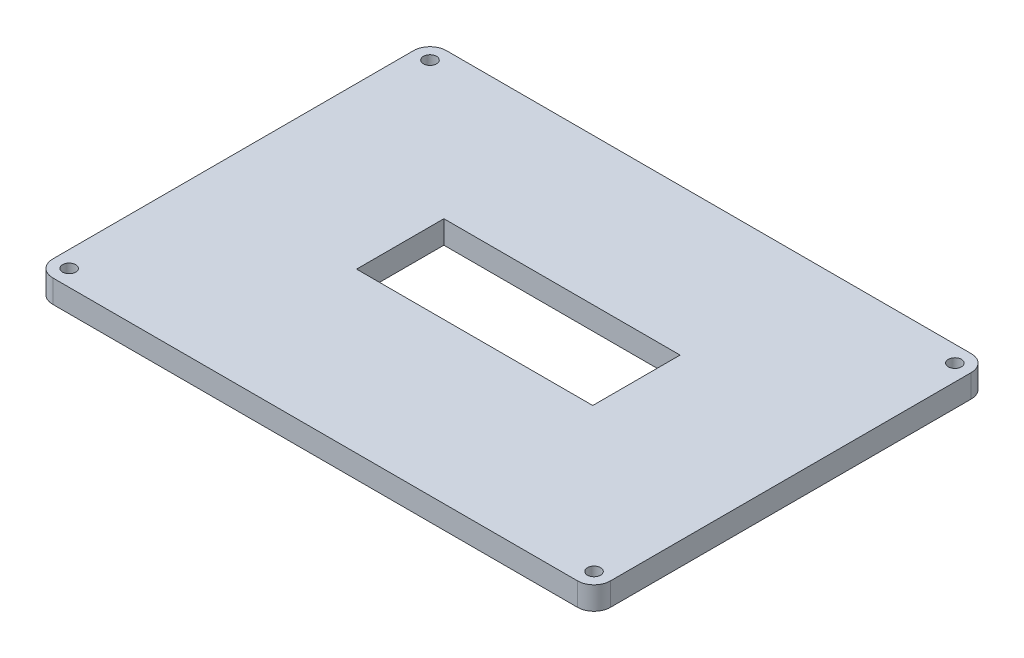
from build123d import *

# Parameters (mm, degrees)
SKETCH1_W           = 170
SKETCH1_H           = 120
BOSS_EXTRUDE1_DEPTH = 7
SKETCH2_W           = 72
SKETCH2_H           = 26.620567464
CUT_EXTRUDE1_DEPTH  = 7
SKETCH3_R           = 2
CUT_EXTRUDE5_DEPTH  = 7
SKETCH7_R           = 2
CUT_EXTRUDE7_DEPTH  = 10
SKETCH6_R           = 2
CUT_EXTRUDE10_DEPTH = 10
SKETCH9_R           = 2
CUT_EXTRUDE11_DEPTH = 10
FILLET1_R           = 5


with BuildPart() as part:
    # Sketch1 → Boss-Extrude1 (new body)
    with BuildSketch(Plane(origin=(0, 0, 0), x_dir=(1, 0, 0), z_dir=(0, 1, 0))):
        Rectangle(SKETCH1_W, SKETCH1_H)
    extrude(amount=BOSS_EXTRUDE1_DEPTH)

    # Sketch2 → Cut-Extrude1 (cut)
    with BuildSketch(Plane(origin=(0, 7, 0), x_dir=(1, 0, 0), z_dir=(0, 1, 0))):
        with Locations((0, 1.926488435)):
            Rectangle(SKETCH2_W, SKETCH2_H)
    extrude(amount=-CUT_EXTRUDE1_DEPTH, mode=Mode.SUBTRACT)

    # Sketch3 → Cut-Extrude5 (cut)
    with BuildSketch(Plane(origin=(0, 7, 0), x_dir=(1, 0, 0), z_dir=(0, 1, 0))):
        with Locations((-80, 55)):
            Circle(SKETCH3_R)
    extrude(amount=-CUT_EXTRUDE5_DEPTH, mode=Mode.SUBTRACT)

    # Sketch7 → Cut-Extrude7 (cut)
    with BuildSketch(Plane(origin=(0, 7, 0), x_dir=(1, 0, 0), z_dir=(0, 1, 0))):
        with Locations((-80, -55)):
            Circle(SKETCH7_R)
    extrude(amount=-CUT_EXTRUDE7_DEPTH, mode=Mode.SUBTRACT)

    # Sketch6 → Cut-Extrude10 (cut)
    with BuildSketch(Plane(origin=(0, 7, 0), x_dir=(1, 0, 0), z_dir=(0, 1, 0))):
        with Locations((80, 55)):
            Circle(SKETCH6_R)
    extrude(amount=-CUT_EXTRUDE10_DEPTH, mode=Mode.SUBTRACT)

    # Sketch9 → Cut-Extrude11 (cut)
    with BuildSketch(Plane(origin=(0, 7, 0), x_dir=(1, 0, 0), z_dir=(0, 1, 0))):
        with Locations((80, -55)):
            Circle(SKETCH9_R)
    extrude(amount=-CUT_EXTRUDE11_DEPTH, mode=Mode.SUBTRACT)

    # Fillet1
    fillet1_edges = [part.edges().sort_by_distance(p)[0] for p in [
        (-85, 3.5, -60),
        (85, 3.5, -60),
        (85, 3.5, 60),
        (-85, 3.5, 60),
    ]]
    fillet(fillet1_edges, radius=FILLET1_R)


solid = part.part
